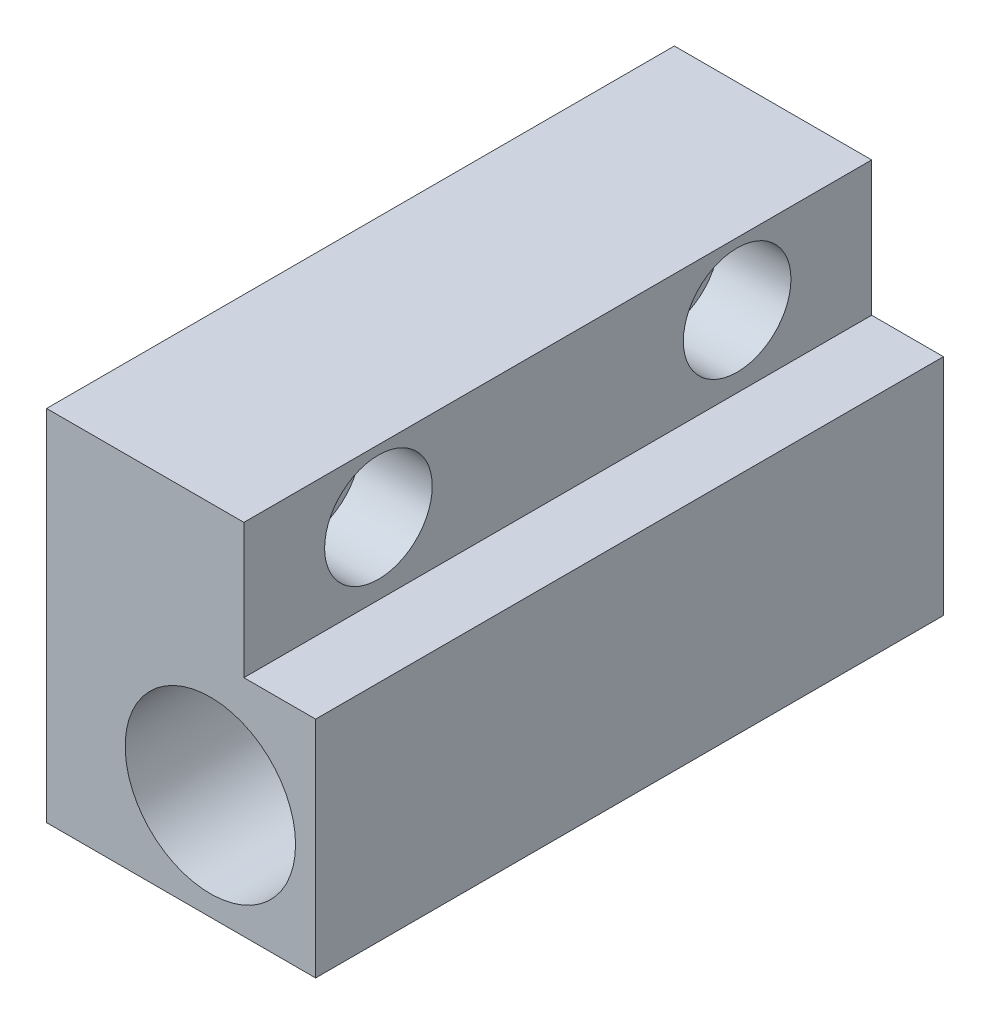
from build123d import *

# Parameters (mm, degrees)
SKETCH_1_W          = 30
SKETCH_1_H          = 40
EXTRUDE_1_DEPTH     = 70
SKETCH_3_R          = 3
CUT_EXTRUDE_1_DEPTH = 70
SKETCH_4_R          = 6
CUT_EXTRUDE_2_DEPTH = 16
SKETCH_5_W          = 8
SKETCH_5_H          = 15
CUT_EXTRUDE_3_DEPTH = 75
SKETCH_2_R          = 9.5
CUT_EXTRUDE_4_DEPTH = 60
SKETCH_6_R          = 5
CUT_EXTRUDE_5_DEPTH = 50


with BuildPart() as part:
    # 草图1 → 凸台-拉伸1 (new body)
    with BuildSketch(Plane.XY):
        with Locations((47.847642857, 10.842857143)):
            Rectangle(SKETCH_1_W, SKETCH_1_H)
    extrude(amount=EXTRUDE_1_DEPTH)

    # 草图3 → 切除-拉伸1 (cut)
    with BuildSketch(Plane(origin=(62.847642857, 0, 0), x_dir=(0, 0, -1), z_dir=(1, 0, 0))):
        with Locations((-55, 23.842857143)):
            Circle(SKETCH_3_R)
        with Locations((-15, 23.842857143)):
            Circle(SKETCH_3_R)
    extrude(amount=-CUT_EXTRUDE_1_DEPTH, mode=Mode.SUBTRACT)

    # 草图4 → 切除-拉伸2 (cut)
    with BuildSketch(Plane(origin=(62.847642857, 0, 0), x_dir=(0, 0, -1), z_dir=(1, 0, 0))):
        with Locations((-55, 23.842857143)):
            Circle(SKETCH_4_R)
        with Locations((-15, 23.842857143)):
            Circle(SKETCH_4_R)
    extrude(amount=-CUT_EXTRUDE_2_DEPTH, mode=Mode.SUBTRACT)

    # 草图5 → 切除-拉伸3 (cut)
    with BuildSketch(Plane.XY.offset(70)):
        with Locations((58.847642857, 23.342857143)):
            Rectangle(SKETCH_5_W, SKETCH_5_H)
    extrude(amount=-CUT_EXTRUDE_3_DEPTH, mode=Mode.SUBTRACT)

    # 草图2 → 切除-拉伸4 (cut)
    with BuildSketch(Plane.XY.offset(70)):
        with Locations((51.107196317, 2.608195772)):
            Circle(SKETCH_2_R)
    extrude(amount=-CUT_EXTRUDE_4_DEPTH, mode=Mode.SUBTRACT)

    # 草图6 → 切除-拉伸5 (cut)
    with BuildSketch(Plane.XY.offset(10)):
        with Locations((51.107196317, 2.608195772)):
            Circle(SKETCH_6_R)
    extrude(amount=-CUT_EXTRUDE_5_DEPTH, mode=Mode.SUBTRACT)


solid = part.part
